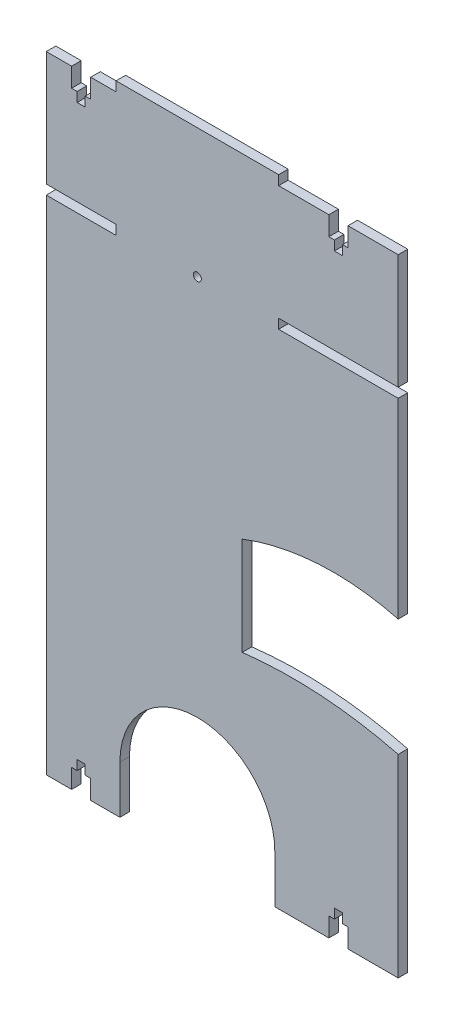
from build123d import *

# Parameters (mm, degrees)
SKETCH2_W               = 184
SKETCH2_H               = 332.5
BOSS_EXTRUDE1_DEPTH     = 5
SKETCH3_W               = 36.5
SKETCH3_H               = 5
SKETCH3_W_2             = 62.5
CUT_EXTRUDE1_DEPTH      = 5
CUT_EXTRUDE2_DEPTH      = 10
SKETCH5_R               = 2.1
CUT_EXTRUDE3_DEPTH      = 10
ENL_V_MAT_EXTRU_2_DEPTH = 10


with BuildPart() as part:
    # Sketch2 → Boss-Extrude1 (new body)
    with BuildSketch(Plane.XY):
        Rectangle(SKETCH2_W, SKETCH2_H)
    extrude(amount=BOSS_EXTRUDE1_DEPTH)

    # Sketch3 → Cut-Extrude1 (cut)
    with BuildSketch(Plane.XY.offset(5)):
        with Locations((-73.75, 163.75)):
            Rectangle(SKETCH3_W, SKETCH3_H)
        with Locations((60.75, 163.75)):
            Rectangle(SKETCH3_W_2, SKETCH3_H)
        with Locations((60.75, 98.75)):
            Rectangle(SKETCH3_W_2, SKETCH3_H)
        with BuildLine():
            Line((27.5, -141.25), (27.5, -166.25))
            Line((27.5, -166.25), (-53.5, -166.25))
            Line((-53.5, -166.25), (-53.5, -141.25))
            ThreePointArc((-53.5, -141.25), (-13, -100.75), (27.5, -141.25))
        make_face()
        with Locations((-73.75, 98.75)):
            Rectangle(SKETCH3_W, SKETCH3_H)
    extrude(amount=-CUT_EXTRUDE1_DEPTH, mode=Mode.SUBTRACT)

    # Sketch4 → Cut-Extrude2 (cut)
    with BuildSketch(Plane.XY.offset(5)):
        Polygon((55.75, 161.25), (55.75, 151.25), (58.65, 151.25), (58.65, 146.25), (62.85, 146.25), (62.85, 151.25), (65.75, 151.25), (65.75, 161.25), align=None)
        Polygon((-78.75, 161.25), (-78.75, 151.25), (-75.85, 151.25), (-75.85, 146.25), (-71.65, 146.25), (-71.65, 151.25), (-68.75, 151.25), (-68.75, 161.25), align=None)
        Polygon((65.75, -166.25), (65.75, -156.25), (62.85, -156.25), (62.85, -151.25), (58.65, -151.25), (58.65, -156.25), (55.75, -156.25), (55.75, -166.25), align=None)
        Polygon((-68.75, -166.25), (-68.75, -156.25), (-71.65, -156.25), (-71.65, -151.25), (-75.85, -151.25), (-75.85, -156.25), (-78.75, -156.25), (-78.75, -166.25), align=None)
    extrude(amount=-CUT_EXTRUDE2_DEPTH, mode=Mode.SUBTRACT)

    # Sketch5 → Cut-Extrude3 (cut)
    with BuildSketch(Plane.XY.offset(5)):
        with Locations((-13, 98.75)):
            Circle(SKETCH5_R)
    extrude(amount=-CUT_EXTRUDE3_DEPTH, mode=Mode.SUBTRACT)

    # Esquisse2 → Enlèv. mat.-Extru.2 (cut)
    with BuildSketch(Plane.XY.offset(5)):
        with BuildLine():
            Line((10.470660362, -8.273773364), (10.470660362, -59.567669296))
            ThreePointArc((10.470660362, -59.567669296), (51.484945295, -58.532619163), (92, -64.995841242))
            Line((92, -64.995841242), (92, -3.75037767))
            ThreePointArc((92, -3.75037767), (50.880784547, 0.378228003), (10.470660362, -8.273773364))
        make_face()
    extrude(amount=-ENL_V_MAT_EXTRU_2_DEPTH, mode=Mode.SUBTRACT)


solid = part.part
